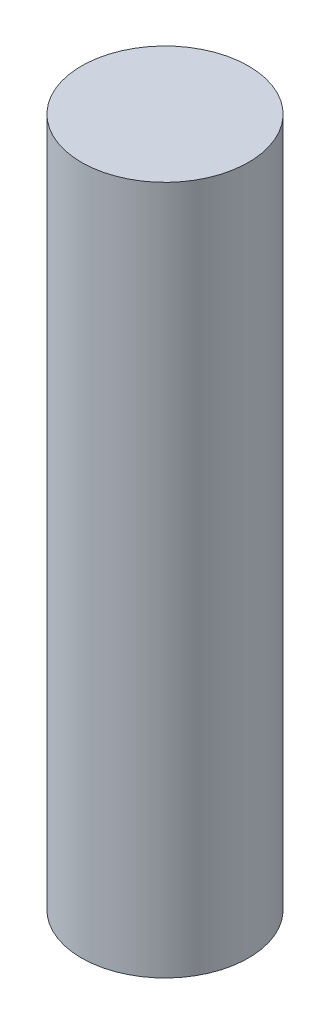
from build123d import *

# Parameters (mm, degrees)
SKETCH1_R           = 2.4
BOSS_EXTRUDE1_DEPTH = 19.8


with BuildPart() as part:
    # Sketch1 → Boss-Extrude1 (new body)
    with BuildSketch(Plane(origin=(0, 0, 0), x_dir=(1, 0, 0), z_dir=(0, 1, 0))):
        with Locations((-35.400459649, 11.846880067)):
            Circle(SKETCH1_R)
    extrude(amount=BOSS_EXTRUDE1_DEPTH)


solid = part.part
